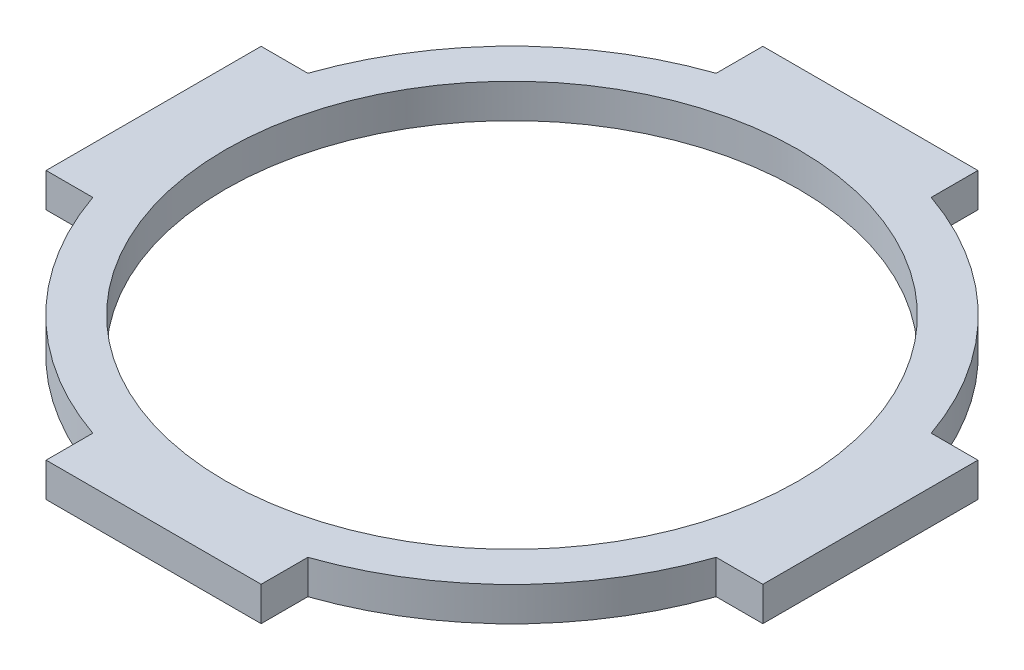
from build123d import *

# Parameters (mm, degrees)
SKETCH1_R           = 46
SKETCH1_R_2         = 40
BOSS_EXTRUDE1_DEPTH = 4.7625
BOSS_EXTRUDE2_DEPTH = 4.7625
CIRPATTERN1_COUNT   = 4


with BuildPart() as part:
    # Sketch1 → Boss-Extrude1 (new body)
    with BuildSketch(Plane(origin=(0, 0, 0), x_dir=(1, 0, 0), z_dir=(0, 1, 0))):
        Circle(SKETCH1_R)
        Circle(SKETCH1_R_2, mode=Mode.SUBTRACT)
    extrude(amount=BOSS_EXTRUDE1_DEPTH)

    # Sketch2 → Boss-Extrude2 (add)
    with BuildSketch(Plane(origin=(0, 4.7625, 0), x_dir=(1, 0, 0), z_dir=(0, 1, 0))):
        with BuildLine():
            Line((-43.48562981, 15), (-50, 15))
            Line((-50, 15), (-50, -15))
            Line((-50, -15), (-43.48562981, -15))
            ThreePointArc((-43.48562981, -15), (-46, 0), (-43.48562981, 15))
        make_face()
    boss_extrude2 = extrude(amount=-BOSS_EXTRUDE2_DEPTH)

    # CirPattern1: Boss-Extrude2 ×4 about axis
    cirpattern1_axis = Axis((0, 0, 0), (0, 1, 0))
    for i in range(1, CIRPATTERN1_COUNT):
        add(boss_extrude2.rotate(cirpattern1_axis, i * 360 / CIRPATTERN1_COUNT))


solid = part.part
